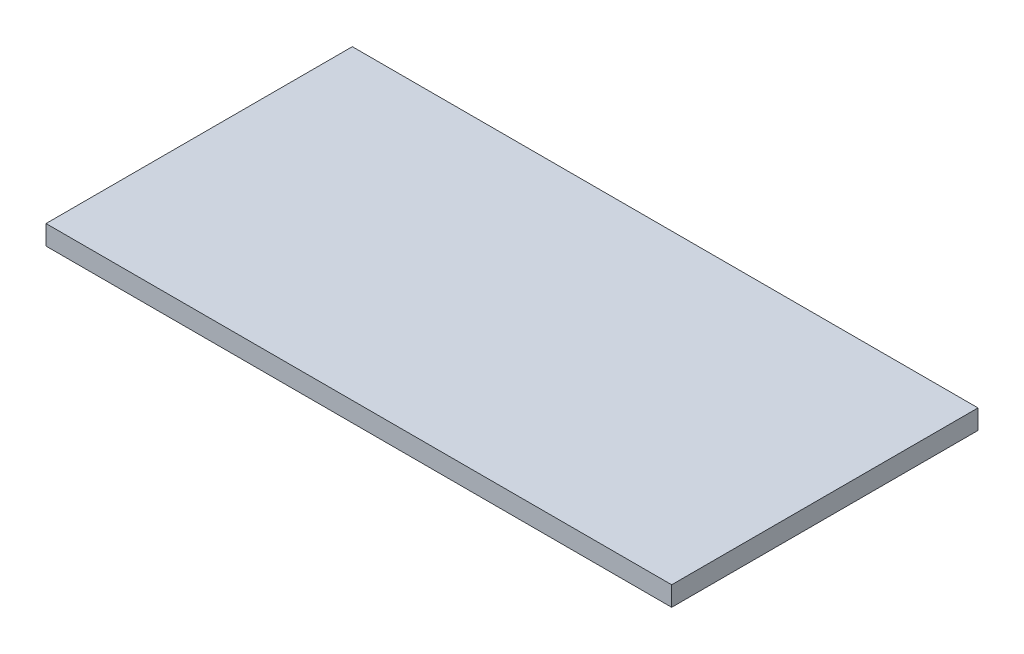
from build123d import *

# Parameters (mm, degrees)
SKETCH_1_W      = 576
SKETCH_1_H      = 282
EXTRUDE_1_DEPTH = 18


with BuildPart() as part:
    # Эскиз1 → Бобышка-Вытянуть1 (new body)
    with BuildSketch(Plane(origin=(0, 0, 0), x_dir=(1, 0, 0), z_dir=(0, 1, 0))):
        Rectangle(SKETCH_1_W, SKETCH_1_H)
    extrude(amount=EXTRUDE_1_DEPTH)


solid = part.part
